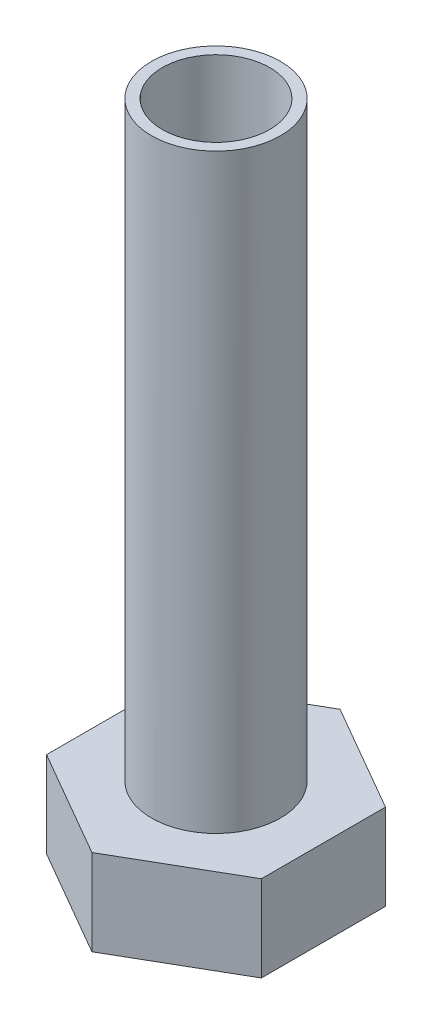
from build123d import *

# Parameters (mm, degrees)
SKETCH1_R           = 3
SKETCH1_R_2         = 2.5
BOSS_EXTRUDE1_DEPTH = 27.5
BOSS_EXTRUDE2_DEPTH = 4


with BuildPart() as part:
    # Sketch1 → Boss-Extrude1 (new body)
    with BuildSketch(Plane(origin=(0, 0, 0), x_dir=(1, 0, 0), z_dir=(0, 1, 0))):
        Circle(SKETCH1_R)
        Circle(SKETCH1_R_2, mode=Mode.SUBTRACT)
    extrude(amount=BOSS_EXTRUDE1_DEPTH)

    # Sketch2 → Boss-Extrude2 (add)
    with BuildSketch(Plane.XZ):
        Polygon((0, 5.773502692), (-5, 2.886751346), (-5, -2.886751346), (0, -5.773502692), (5, -2.886751346), (5, 2.886751346), align=None)
    extrude(amount=BOSS_EXTRUDE2_DEPTH)


solid = part.part
